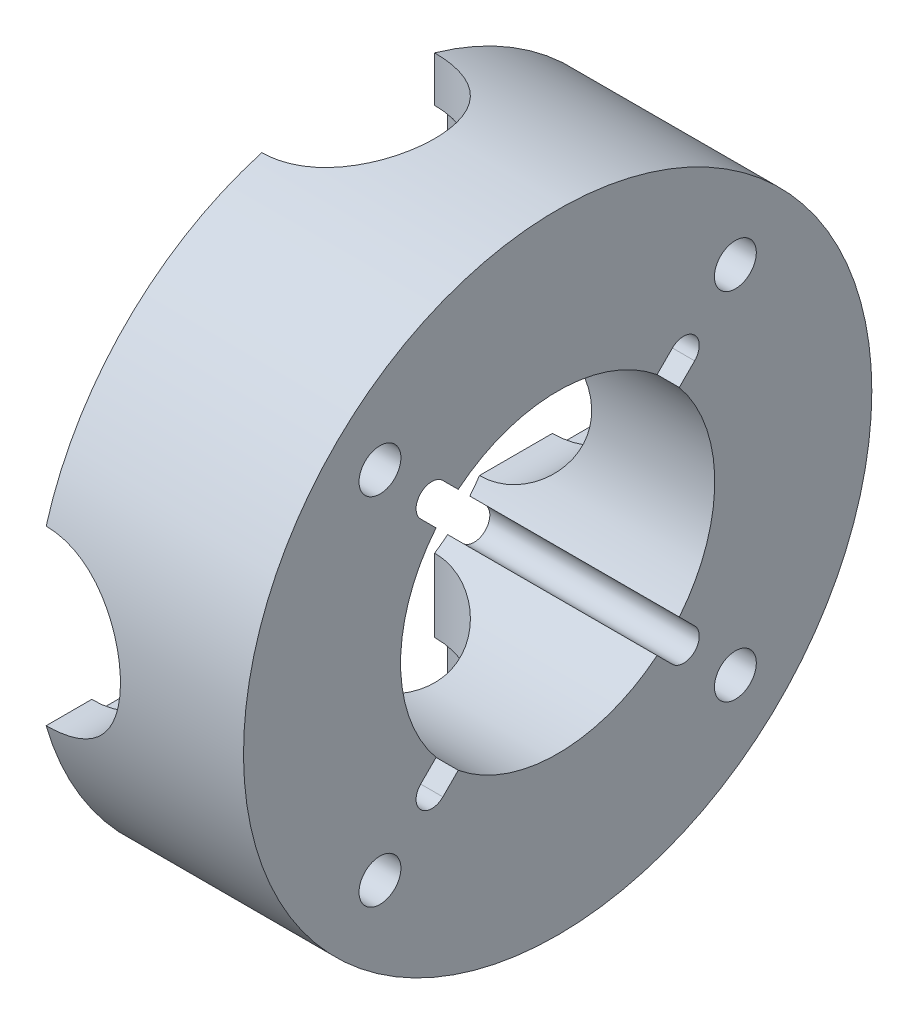
from build123d import *

# Parameters (mm, degrees)
SKETCH1_R           = 30
SKETCH1_R_2         = 15
BOSS_EXTRUDE1_DEPTH = 40
SKETCH2_R           = 9.5
CUT_EXTRUDE1_DEPTH  = 2.5
SKETCH3_R           = 8.25
CUT_EXTRUDE2_DEPTH  = 15
CIRPATTERN1_COUNT   = 4
SKETCH4_R           = 2
CUT_EXTRUDE3_DEPTH  = 47.904157769
CUT_EXTRUDE4_DEPTH  = 47.904157769


with BuildPart() as part:
    # Sketch1 → Boss-Extrude1 (new body)
    with BuildSketch(Plane(origin=(0, 0, 0), x_dir=(0, 0, -1), z_dir=(1, 0, 0))):
        Circle(SKETCH1_R)
        Circle(SKETCH1_R_2, mode=Mode.SUBTRACT)
    extrude(amount=BOSS_EXTRUDE1_DEPTH)

    # Sketch2 → Cut-Extrude1 (cut, symmetric)
    with BuildSketch(Plane.XY.offset(22)):
        with Locations((20, 0)):
            Circle(SKETCH2_R)
    cut_extrude1 = extrude(amount=CUT_EXTRUDE1_DEPTH, both=True, mode=Mode.SUBTRACT)

    # Sketch3 → Cut-Extrude2 (cut, symmetric)
    with BuildSketch(Plane.XY.offset(22)):
        with Locations((20, 0)):
            Circle(SKETCH3_R)
    cut_extrude2 = extrude(amount=CUT_EXTRUDE2_DEPTH, both=True, mode=Mode.SUBTRACT)

    # CirPattern1: Cut-Extrude1, Cut-Extrude2 ×4 about axis
    cirpattern1_axis = Axis((0, 0, 0), (1, 0, 0))
    add([cut_extrude1.rotate(cirpattern1_axis, i * 360 / CIRPATTERN1_COUNT) for i in range(1, CIRPATTERN1_COUNT)], mode=Mode.SUBTRACT)
    add([cut_extrude2.rotate(cirpattern1_axis, i * 360 / CIRPATTERN1_COUNT) for i in range(1, CIRPATTERN1_COUNT)], mode=Mode.SUBTRACT)


with BuildPart() as body_2:
    # Split2: the piece on the far side of the plane
    add(part.part)
    split(bisect_by=Plane(origin=(20, 0, 0), x_dir=(0, 0, 1), z_dir=(1, 0, 0)), keep=Keep.BOTTOM)


with BuildPart() as part_1:
    add(part.part)

    # Split2
    split(bisect_by=Plane(origin=(20, 0, 0), x_dir=(0, 0, 1), z_dir=(1, 0, 0)), keep=Keep.TOP)

    # Sketch4 → Cut-Extrude3 (cut, through all)
    with BuildSketch(Plane(origin=(40, 0, 0), x_dir=(0, 0, -1), z_dir=(1, 0, 0))):
        with Locations((-16.970562748, 16.970562748)):
            Circle(SKETCH4_R)
        with Locations((16.970562748, 16.970562748)):
            Circle(SKETCH4_R)
        with Locations((16.970562748, -16.970562748)):
            Circle(SKETCH4_R)
        with Locations((-16.970562748, -16.970562748)):
            Circle(SKETCH4_R)
    extrude(amount=-CUT_EXTRUDE3_DEPTH, mode=Mode.SUBTRACT)

    # Sketch5 → Cut-Extrude4 (cut, through all)
    with BuildSketch(Plane.ZY.offset(-20)):
        with BuildLine():
            ThreePointArc((-11.614095631, 9.492775288), (-11.124297731, 10.062305899), (-10.606601718, 10.606601718))
            ThreePointArc((-10.606601718, 10.606601718), (-10.062305899, 11.124297731), (-9.492775288, 11.614095631))
            Line((-9.492775288, 11.614095631), (-10.960155108, 13.081475452))
            ThreePointArc((-10.960155108, 13.081475452), (-13.081475452, 13.081475452), (-13.081475452, 10.960155108))
            Line((-13.081475452, 10.960155108), (-11.614095631, 9.492775288))
        make_face()
        with BuildLine():
            ThreePointArc((13.081475452, 10.960155108), (13.081475452, 13.081475452), (10.960155108, 13.081475452))
            Line((10.960155108, 13.081475452), (9.492775288, 11.614095631))
            ThreePointArc((9.492775288, 11.614095631), (10.606601718, 10.606601718), (11.614095631, 9.492775288))
            Line((11.614095631, 9.492775288), (13.081475452, 10.960155108))
        make_face()
        with BuildLine():
            ThreePointArc((10.960155108, -13.081475452), (13.081475452, -13.081475452), (13.081475452, -10.960155108))
            Line((13.081475452, -10.960155108), (11.614095631, -9.492775288))
            ThreePointArc((11.614095631, -9.492775288), (10.606601718, -10.606601718), (9.492775288, -11.614095631))
            Line((9.492775288, -11.614095631), (10.960155108, -13.081475452))
        make_face()
        with BuildLine():
            ThreePointArc((-13.081475452, -10.960155108), (-13.081475452, -13.081475452), (-10.960155108, -13.081475452))
            Line((-10.960155108, -13.081475452), (-9.492775288, -11.614095631))
            ThreePointArc((-9.492775288, -11.614095631), (-10.606601718, -10.606601718), (-11.614095631, -9.492775288))
            Line((-11.614095631, -9.492775288), (-13.081475452, -10.960155108))
        make_face()
    extrude(amount=-CUT_EXTRUDE4_DEPTH, mode=Mode.SUBTRACT)


solid = part_1.part
